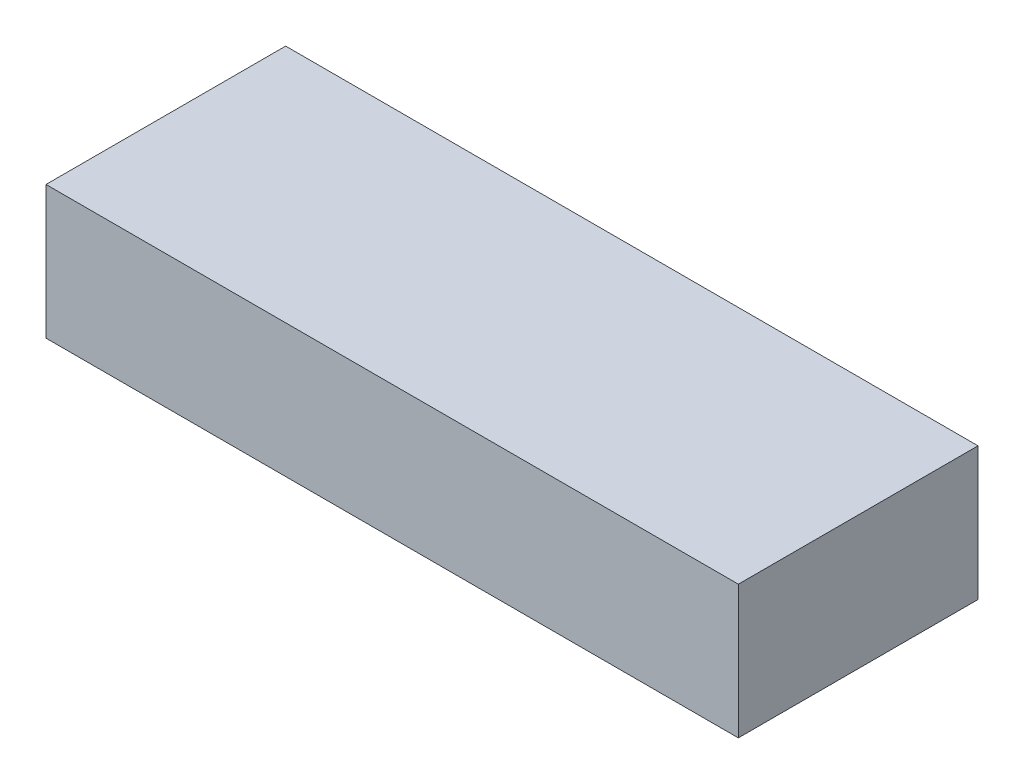
from build123d import *

# Parameters (mm, degrees)
ESQUISSE1_W      = 26
ESQUISSE1_H      = 5
EXTRUSION1_DEPTH = 9


with BuildPart() as part:
    # Esquisse1 → Extrusion1 (new body)
    with BuildSketch(Plane.XY):
        Rectangle(ESQUISSE1_W, ESQUISSE1_H)
    extrude(amount=EXTRUSION1_DEPTH)


solid = part.part
